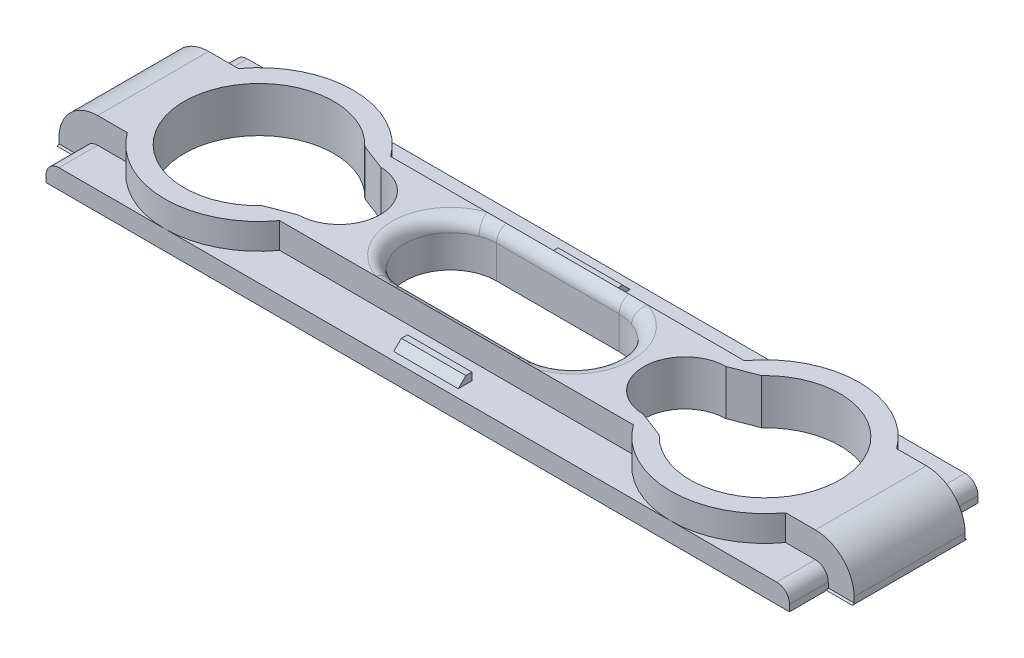
from build123d import *

# Parameters (mm, degrees)
SKETCH_2_W          = 61.6
SKETCH_2_H          = 54.8
EXTRUDE_1_DEPTH     = 1.5
SKETCH_2_4_R        = 1.849118688
EXTRUDE_3_DEPTH     = 3.3
SKETCH_6_W          = 14.6
SKETCH_6_H          = 54.8
EXTRUDE_4_DEPTH     = 3.5
EXTRUDE_START       = -3.5
SKETCH_9_W          = 14.6
SKETCH_9_H          = 54.8
EXTRUDE_6_DEPTH     = 3.5
SKETCH_10_W         = 61.6
SKETCH_10_H         = 14.6
EXTRUDE_7_DEPTH     = 3.5
SKETCH_11_W         = 61.6
SKETCH_11_H         = 14.6
EXTRUDE_8_DEPTH     = 3.5
FILLET_1_R          = 3
CUT_EXTRUDE_1_DEPTH = 3
CUT_EXTRUDE_2_DEPTH = 3
EXTRUDE_9_DEPTH     = 2
EXTRUDE_10_DEPTH    = 2
EXTRUDE_11_DEPTH    = 2
EXTRUDE_12_DEPTH    = 2
EXTRUDE_13_DEPTH    = 2.5
EXTRUDE_14_DEPTH    = 2.5
SKETCH_28_W         = 1.75
SKETCH_28_H         = 12
SKETCH_28_W_2       = 3
SKETCH_28_H_2       = 2.5
EXTRUDE_15_DEPTH    = 3.8
SKETCH_29_W         = 3
SKETCH_29_H         = 3.2
EXTRUDE_16_DEPTH    = 1
CUT_EXTRUDE_4_DEPTH = 1.5
CUT_EXTRUDE_5_DEPTH = 0.2
FILLET_2_R          = 2
FILLET_3_R          = 1.2
FILLET_4_R          = 1
CUT_EXTRUDE_START   = -19.4
SKETCH_32_W         = 75.859078002
SKETCH_32_H         = 54.519170687
CUT_EXTRUDE_6_DEPTH = 19.4


with BuildPart() as part:
    # ｽｹｯﾁ2 → ﾎﾞｽ - 押し出し1 (new body)
    with BuildSketch(Plane.XY):
        with Locations((27, 20)):
            Rectangle(SKETCH_2_W, SKETCH_2_H)
        with BuildLine():
            Line((17.396467493, 32.098090349), (17.396467493, 34.884847493))
            ThreePointArc((17.396467493, 34.884847493), (27, 44.48838), (36.603532507, 34.884847493))
            Line((36.603532507, 34.884847493), (36.603532507, 32.098090349))
            ThreePointArc((36.603532507, 32.098090349), (27, 22.494557841), (17.396467493, 32.098090349))
        make_face(mode=Mode.SUBTRACT)
        with BuildLine():
            Line((17.396467493, 7.901909651), (17.396467493, 5.115152507))
            ThreePointArc((17.396467493, 5.115152507), (27, -4.48838), (36.603532507, 5.115152507))
            Line((36.603532507, 5.115152507), (36.603532507, 7.901909651))
            ThreePointArc((36.603532507, 7.901909651), (27, 17.505442159), (17.396467493, 7.901909651))
        make_face(mode=Mode.SUBTRACT)
        with BuildLine():
            Line((46.11976018, 13.198097812), (44.853626262, 13.198097812))
            ThreePointArc((44.853626262, 13.198097812), (38.051724073, 20), (44.853626262, 26.801902188))
            Line((44.853626262, 26.801902188), (46.11976018, 26.801902188))
            ThreePointArc((46.11976018, 26.801902188), (52.921662369, 20), (46.11976018, 13.198097812))
        make_face(mode=Mode.SUBTRACT)
        with BuildLine():
            Line((7.88023982, 13.198097812), (9.146373738, 13.198097812))
            ThreePointArc((9.146373738, 13.198097812), (15.948275927, 20), (9.146373738, 26.801902188))
            Line((9.146373738, 26.801902188), (7.88023982, 26.801902188))
            ThreePointArc((7.88023982, 26.801902188), (1.078337631, 20), (7.88023982, 13.198097812))
        make_face(mode=Mode.SUBTRACT)
    extrude(amount=EXTRUDE_1_DEPTH)

    # ｽｹｯﾁ2<4> → ﾎﾞｽ - 押し出し3 (add)
    with BuildSketch(Plane.XY):
        with Locations((2, 38)):
            Circle(SKETCH_2_4_R)
        with Locations((2, 2)):
            Circle(SKETCH_2_4_R)
        with Locations((52, 2)):
            Circle(SKETCH_2_4_R)
        with Locations((52, 38)):
            Circle(SKETCH_2_4_R)
    extrude(amount=EXTRUDE_3_DEPTH)

    # ｽｹｯﾁ6 → ﾎﾞｽ - 押し出し4 (add)
    with BuildSketch(Plane.ZY.offset(3.8)):
        with Locations((-5.8, 20)):
            Rectangle(SKETCH_6_W, SKETCH_6_H)
        with BuildLine():
            Line((-3.521492008, 23.1), (-3.521492008, 16.9))
            ThreePointArc((-3.521492008, 16.9), (-5.8, 14.621492008), (-8.078507992, 16.9))
            Line((-8.078507992, 16.9), (-8.078507992, 23.1))
            ThreePointArc((-8.078507992, 23.1), (-5.8, 25.378507992), (-3.521492008, 23.1))
        make_face(mode=Mode.SUBTRACT)
        with BuildLine():
            Line((-9.770178394, 33.871799021), (-8.999779069, 31.862398009))
            ThreePointArc((-8.999779069, 31.862398009), (-5.8, 28.7), (-2.600220931, 31.862398009))
            Line((-2.600220931, 31.862398009), (-1.829821606, 33.871799021))
            ThreePointArc((-1.829821606, 33.871799021), (-5.8, 43.9), (-9.770178394, 33.871799021))
        make_face(mode=Mode.SUBTRACT)
        with BuildLine():
            Line((-2.600220931, 8.137601991), (-1.829821606, 6.128200979))
            ThreePointArc((-1.829821606, 6.128200979), (-5.8, -3.9), (-9.770178394, 6.128200979))
            Line((-9.770178394, 6.128200979), (-8.999779069, 8.137601991))
            ThreePointArc((-8.999779069, 8.137601991), (-5.8, 11.3), (-2.600220931, 8.137601991))
        make_face(mode=Mode.SUBTRACT)
    extrude(amount=-EXTRUDE_4_DEPTH)

    # ｽｹｯﾁ9 → ﾎﾞｽ - 押し出し6 (add)
    with BuildSketch(Plane(origin=(57.8, 0, 0), x_dir=(0, 0, -1), z_dir=(1, 0, 0)).offset(EXTRUDE_START)):
        with Locations((5.8, 20)):
            Rectangle(SKETCH_9_W, SKETCH_9_H)
        with BuildLine():
            Line((8.999779069, 31.862398009), (9.770178394, 33.871799021))
            ThreePointArc((9.770178394, 33.871799021), (5.8, 43.9), (1.829821606, 33.871799021))
            Line((1.829821606, 33.871799021), (2.600220931, 31.862398009))
            ThreePointArc((2.600220931, 31.862398009), (5.8, 28.7), (8.999779069, 31.862398009))
        make_face(mode=Mode.SUBTRACT)
        with BuildLine():
            Line((2.600220931, 8.137601991), (1.829821606, 6.128200979))
            ThreePointArc((1.829821606, 6.128200979), (5.8, -3.9), (9.770178394, 6.128200979))
            Line((9.770178394, 6.128200979), (8.999779069, 8.137601991))
            ThreePointArc((8.999779069, 8.137601991), (5.8, 11.3), (2.600220931, 8.137601991))
        make_face(mode=Mode.SUBTRACT)
        with BuildLine():
            Line((3.521492008, 23.1), (3.521492008, 16.9))
            ThreePointArc((3.521492008, 16.9), (5.8, 14.621492008), (8.078507992, 16.9))
            Line((8.078507992, 16.9), (8.078507992, 23.1))
            ThreePointArc((8.078507992, 23.1), (5.8, 25.378507992), (3.521492008, 23.1))
        make_face(mode=Mode.SUBTRACT)
    extrude(amount=EXTRUDE_6_DEPTH)

    # ｽｹｯﾁ10 → ﾎﾞｽ - 押し出し7 (add)
    with BuildSketch(Plane.XZ.offset(7.4)):
        with Locations((27, -5.8)):
            Rectangle(SKETCH_10_W, SKETCH_10_H)
        with BuildLine():
            Line((22.25, -2.25), (31.75, -2.25))
            ThreePointArc((31.75, -2.25), (35.3, -5.8), (31.75, -9.35))
            Line((31.75, -9.35), (22.25, -9.35))
            ThreePointArc((22.25, -9.35), (18.7, -5.8), (22.25, -2.25))
        make_face(mode=Mode.SUBTRACT)
        with BuildLine():
            Line((11.628200979, -9.770178394), (13.637601991, -8.999779069))
            ThreePointArc((13.637601991, -8.999779069), (16.8, -5.8), (13.637601991, -2.600220931))
            Line((13.637601991, -2.600220931), (11.628200979, -1.829821606))
            ThreePointArc((11.628200979, -1.829821606), (1.6, -5.8), (11.628200979, -9.770178394))
        make_face(mode=Mode.SUBTRACT)
        with BuildLine():
            Line((40.362398009, -2.600220931), (42.371799021, -1.829821606))
            ThreePointArc((42.371799021, -1.829821606), (52.4, -5.8), (42.371799021, -9.770178394))
            Line((42.371799021, -9.770178394), (40.362398009, -8.999779069))
            ThreePointArc((40.362398009, -8.999779069), (37.2, -5.8), (40.362398009, -2.600220931))
        make_face(mode=Mode.SUBTRACT)
    extrude(amount=-EXTRUDE_7_DEPTH)

    # ｽｹｯﾁ11 → ﾎﾞｽ - 押し出し8 (add)
    with BuildSketch(Plane(origin=(0, 47.4, 0), x_dir=(1, 0, 0), z_dir=(0, 1, 0))):
        with Locations((27, 5.8)):
            Rectangle(SKETCH_11_W, SKETCH_11_H)
        with BuildLine():
            Line((40.362398009, 2.600220931), (42.371799021, 1.829821606))
            ThreePointArc((42.371799021, 1.829821606), (52.4, 5.8), (42.371799021, 9.770178394))
            Line((42.371799021, 9.770178394), (40.362398009, 8.999779069))
            ThreePointArc((40.362398009, 8.999779069), (37.2, 5.8), (40.362398009, 2.600220931))
        make_face(mode=Mode.SUBTRACT)
        with BuildLine():
            Line((13.637601991, 8.999779069), (11.628200979, 9.770178394))
            ThreePointArc((11.628200979, 9.770178394), (1.6, 5.8), (11.628200979, 1.829821606))
            Line((11.628200979, 1.829821606), (13.637601991, 2.600220931))
            ThreePointArc((13.637601991, 2.600220931), (16.8, 5.8), (13.637601991, 8.999779069))
        make_face(mode=Mode.SUBTRACT)
        with BuildLine():
            Line((22.25, 2.25), (31.75, 2.25))
            ThreePointArc((31.75, 2.25), (35.3, 5.8), (31.75, 9.35))
            Line((31.75, 9.35), (22.25, 9.35))
            ThreePointArc((22.25, 9.35), (18.7, 5.8), (22.25, 2.25))
        make_face(mode=Mode.SUBTRACT)
    extrude(amount=-EXTRUDE_8_DEPTH)

    # ﾌｨﾚｯﾄ1
    fillet_1_edges = [part.edges().sort_by_distance(p)[0] for p in [
        (57.8, 47.4, -5.8),
        (-3.8, 47.4, -5.8),
        (-3.8, -7.4, -5.8),
        (57.8, -7.4, -5.8),
    ]]
    fillet(fillet_1_edges, radius=FILLET_1_R)

    # ｽｹｯﾁ12 → ｶｯﾄ - 押し出し1 (cut)
    with BuildSketch(Plane(origin=(0, 0, -13.1), x_dir=(-1, 0, 0), z_dir=(0, 0, -1))):
        with BuildLine():
            Line((-54.8, -7.4), (0.8, -7.4))
            ThreePointArc((0.8, -7.4), (2.921320344, -6.521320344), (3.8, -4.4))
            Line((3.8, -4.4), (3.8, 44.4))
            ThreePointArc((3.8, 44.4), (2.921320344, 46.521320344), (0.8, 47.4))
            Line((0.8, 47.4), (-54.8, 47.4))
            ThreePointArc((-54.8, 47.4), (-56.921320344, 46.521320344), (-57.8, 44.4))
            Line((-57.8, 44.4), (-57.8, -4.4))
            ThreePointArc((-57.8, -4.4), (-56.921320344, -6.521320344), (-54.8, -7.4))
        make_face()
        with BuildLine():
            Line((-55.8, 44.4), (-55.8, -4.4))
            ThreePointArc((-55.8, -4.4), (-55.507106781, -5.107106781), (-54.8, -5.4))
            Line((-54.8, -5.4), (0.8, -5.4))
            ThreePointArc((0.8, -5.4), (1.507106781, -5.107106781), (1.8, -4.4))
            Line((1.8, -4.4), (1.8, 44.4))
            ThreePointArc((1.8, 44.4), (1.507106781, 45.107106781), (0.8, 45.4))
            Line((0.8, 45.4), (-54.8, 45.4))
            ThreePointArc((-54.8, 45.4), (-55.507106781, 45.107106781), (-55.8, 44.4))
        make_face(mode=Mode.SUBTRACT)
    extrude(amount=-CUT_EXTRUDE_1_DEPTH, mode=Mode.SUBTRACT)

    # ｽｹｯﾁ22 → ｶｯﾄ - 押し出し2 (cut)
    with BuildSketch(Plane.XY.offset(1.5)):
        with BuildLine():
            Line((-3.8, 44.4), (-3.8, -4.4))
            ThreePointArc((-3.8, -4.4), (-2.921320344, -6.521320344), (-0.8, -7.4))
            Line((-0.8, -7.4), (54.8, -7.4))
            ThreePointArc((54.8, -7.4), (56.921320344, -6.521320344), (57.8, -4.4))
            Line((57.8, -4.4), (57.8, 44.4))
            ThreePointArc((57.8, 44.4), (56.921320344, 46.521320344), (54.8, 47.4))
            Line((54.8, 47.4), (-0.8, 47.4))
            ThreePointArc((-0.8, 47.4), (-2.921320344, 46.521320344), (-3.8, 44.4))
        make_face()
        with BuildLine():
            Line((-1.8, 44.4), (-1.8, -4.4))
            ThreePointArc((-1.8, -4.4), (-1.507106781, -5.107106781), (-0.8, -5.4))
            Line((-0.8, -5.4), (54.8, -5.4))
            ThreePointArc((54.8, -5.4), (55.507106781, -5.107106781), (55.8, -4.4))
            Line((55.8, -4.4), (55.8, 44.4))
            ThreePointArc((55.8, 44.4), (55.507106781, 45.107106781), (54.8, 45.4))
            Line((54.8, 45.4), (-0.8, 45.4))
            ThreePointArc((-0.8, 45.4), (-1.507106781, 45.107106781), (-1.8, 44.4))
        make_face(mode=Mode.SUBTRACT)
    extrude(amount=-CUT_EXTRUDE_2_DEPTH, mode=Mode.SUBTRACT)

    # ｽｹｯﾁ21 → ﾎﾞｽ - 押し出し9 (add)
    with BuildSketch(Plane.XZ.offset(7.4)):
        with BuildLine():
            Line((1.500847518, -10.1), (3.507699909, -10.1))
            ThreePointArc((3.507699909, -10.1), (7.4, -11.6), (11.292300091, -10.1))
            Line((11.292300091, -10.1), (13.299152482, -10.1))
            ThreePointArc((13.299152482, -10.1), (7.4, -13.1), (1.500847518, -10.1))
        make_face()
        with BuildLine():
            Line((11.292300091, -1.5), (13.299152482, -1.5))
            ThreePointArc((13.299152482, -1.5), (7.4, 1.5), (1.500847518, -1.5))
            Line((1.500847518, -1.5), (3.507699909, -1.5))
            ThreePointArc((3.507699909, -1.5), (7.4, 0), (11.292300091, -1.5))
        make_face()
        with BuildLine():
            Line((42.707699909, -10.1), (40.700847518, -10.1))
            ThreePointArc((40.700847518, -10.1), (46.6, -13.1), (52.499152482, -10.1))
            Line((52.499152482, -10.1), (50.492300091, -10.1))
            ThreePointArc((50.492300091, -10.1), (46.6, -11.6), (42.707699909, -10.1))
        make_face()
        with BuildLine():
            Line((52.499152482, -1.5), (50.492300091, -1.5))
            ThreePointArc((50.492300091, -1.5), (46.6, 0), (42.707699909, -1.5))
            Line((42.707699909, -1.5), (40.700847518, -1.5))
            ThreePointArc((40.700847518, -1.5), (46.6, 1.5), (52.499152482, -1.5))
        make_face()
    extrude(amount=-EXTRUDE_9_DEPTH)

    # ｽｹｯﾁ23 → ﾎﾞｽ - 押し出し10 (add)
    with BuildSketch(Plane(origin=(0, 47.4, 0), x_dir=(1, 0, 0), z_dir=(0, 1, 0))):
        with BuildLine():
            Line((1.500847518, 10.1), (3.507699909, 10.1))
            ThreePointArc((3.507699909, 10.1), (7.4, 11.6), (11.292300091, 10.1))
            Line((11.292300091, 10.1), (13.299152482, 10.1))
            ThreePointArc((13.299152482, 10.1), (7.4, 13.1), (1.500847518, 10.1))
        make_face()
        with BuildLine():
            Line((52.499152482, 1.5), (50.492300091, 1.5))
            ThreePointArc((50.492300091, 1.5), (46.6, 0), (42.707699909, 1.5))
            Line((42.707699909, 1.5), (40.700847518, 1.5))
            ThreePointArc((40.700847518, 1.5), (46.6, -1.5), (52.499152482, 1.5))
        make_face()
        with BuildLine():
            Line((40.700847518, 10.1), (42.707699909, 10.1))
            ThreePointArc((42.707699909, 10.1), (46.6, 11.6), (50.492300091, 10.1))
            Line((50.492300091, 10.1), (52.499152482, 10.1))
            ThreePointArc((52.499152482, 10.1), (46.6, 13.1), (40.700847518, 10.1))
        make_face()
        with BuildLine():
            Line((13.299152482, 1.5), (11.292300091, 1.5))
            ThreePointArc((11.292300091, 1.5), (7.4, 0), (3.507699909, 1.5))
            Line((3.507699909, 1.5), (1.500847518, 1.5))
            ThreePointArc((1.500847518, 1.5), (7.4, -1.5), (13.299152482, 1.5))
        make_face()
    extrude(amount=-EXTRUDE_10_DEPTH)

    # ｽｹｯﾁ24 → ﾎﾞｽ - 押し出し11 (add)
    with BuildSketch(Plane(origin=(57.8, 0, 0), x_dir=(0, 0, -1), z_dir=(1, 0, 0))):
        with BuildLine():
            Line((1.5, 41.992300091), (1.5, 43.999152482))
            ThreePointArc((1.5, 43.999152482), (-1.5, 38.1), (1.5, 32.200847518))
            Line((1.5, 32.200847518), (1.5, 34.207699909))
            ThreePointArc((1.5, 34.207699909), (0, 38.1), (1.5, 41.992300091))
        make_face()
        with BuildLine():
            Line((10.1, 32.200847518), (10.1, 34.207699909))
            ThreePointArc((10.1, 34.207699909), (11.6, 38.1), (10.1, 41.992300091))
            Line((10.1, 41.992300091), (10.1, 43.999152482))
            ThreePointArc((10.1, 43.999152482), (13.1, 38.1), (10.1, 32.200847518))
        make_face()
        with BuildLine():
            Line((10.1, -1.992300091), (10.1, -3.999152482))
            ThreePointArc((10.1, -3.999152482), (13.1, 1.9), (10.1, 7.799152482))
            Line((10.1, 7.799152482), (10.1, 5.792300091))
            ThreePointArc((10.1, 5.792300091), (11.6, 1.9), (10.1, -1.992300091))
        make_face()
        with BuildLine():
            Line((1.5, 7.799152482), (1.5, 5.792300091))
            ThreePointArc((1.5, 5.792300091), (0, 1.9), (1.5, -1.992300091))
            Line((1.5, -1.992300091), (1.5, -3.999152482))
            ThreePointArc((1.5, -3.999152482), (-1.5, 1.9), (1.5, 7.799152482))
        make_face()
    extrude(amount=-EXTRUDE_11_DEPTH)

    # ｽｹｯﾁ25 → ﾎﾞｽ - 押し出し12 (add)
    with BuildSketch(Plane.ZY.offset(3.8)):
        with BuildLine():
            Line((-1.5, 43.999152482), (-1.5, 41.992300091))
            ThreePointArc((-1.5, 41.992300091), (0, 38.1), (-1.5, 34.207699909))
            Line((-1.5, 34.207699909), (-1.5, 32.200847518))
            ThreePointArc((-1.5, 32.200847518), (1.5, 38.1), (-1.5, 43.999152482))
        make_face()
        with BuildLine():
            Line((-1.5, 7.799152482), (-1.5, 5.792300091))
            ThreePointArc((-1.5, 5.792300091), (0, 1.9), (-1.5, -1.992300091))
            Line((-1.5, -1.992300091), (-1.5, -3.999152482))
            ThreePointArc((-1.5, -3.999152482), (1.5, 1.9), (-1.5, 7.799152482))
        make_face()
        with BuildLine():
            Line((-10.1, -3.999152482), (-10.1, -1.992300091))
            ThreePointArc((-10.1, -1.992300091), (-11.6, 1.9), (-10.1, 5.792300091))
            Line((-10.1, 5.792300091), (-10.1, 7.799152482))
            ThreePointArc((-10.1, 7.799152482), (-13.1, 1.9), (-10.1, -3.999152482))
        make_face()
        with BuildLine():
            Line((-10.1, 32.200847518), (-10.1, 34.207699909))
            ThreePointArc((-10.1, 34.207699909), (-11.6, 38.1), (-10.1, 41.992300091))
            Line((-10.1, 41.992300091), (-10.1, 43.999152482))
            ThreePointArc((-10.1, 43.999152482), (-13.1, 38.1), (-10.1, 32.200847518))
        make_face()
    extrude(amount=-EXTRUDE_12_DEPTH)

    # ｽｹｯﾁ26 → ﾎﾞｽ - 押し出し13 (add, symmetric)
    with BuildSketch(Plane(origin=(0, 20, 0), x_dir=(1, 0, 0), z_dir=(0, 1, 0))):
        Polygon((56.388664164, -0.246601917), (56.388664164, 0.223398083), (55.8, 0.223398083), (55.8, -0.835266081), align=None)
        Polygon((55.8, 11.376601917), (56.388664164, 11.376601917), (56.388664164, 11.846601917), (55.8, 12.435266081), align=None)
        Polygon((-2.388664164, 11.846601917), (-2.388664164, 11.376601917), (-1.8, 11.376601917), (-1.8, 12.435266081), align=None)
        Polygon((-1.8, 0.223398083), (-2.388664164, 0.223398083), (-2.388664164, -0.246601917), (-1.8, -0.835266081), align=None)
    extrude(amount=EXTRUDE_13_DEPTH, both=True)

    # ｽｹｯﾁ27 → ﾎﾞｽ - 押し出し14 (add, symmetric)
    with BuildSketch(Plane.ZY.offset(-27)):
        Polygon((0.271335836, 45.988664164), (-0.198664164, 45.988664164), (-0.198664164, 45.4), (0.86, 45.4), align=None)
        Polygon((-11.401335836, 45.4), (-12.46, 45.4), (-11.871335836, 45.988664164), (-11.401335836, 45.988664164), align=None)
        Polygon((-11.401335836, -5.4), (-11.401335836, -5.988664164), (-11.871335836, -5.988664164), (-12.46, -5.4), align=None)
        Polygon((-0.198664164, -5.988664164), (-0.198664164, -5.4), (0.86, -5.4), (0.271335836, -5.988664164), align=None)
    extrude(amount=EXTRUDE_14_DEPTH, both=True)

    # ｽｹｯﾁ28 → ﾎﾞｽ - 押し出し15 (add)
    with BuildSketch(Plane.XY.offset(1.5)):
        with Locations((-0.925, 20)):
            Rectangle(SKETCH_28_W, SKETCH_28_H)
        with Locations((54.925, 20)):
            Rectangle(SKETCH_28_W, SKETCH_28_H)
        with Locations((5.85, 41.25)):
            Rectangle(SKETCH_28_W_2, SKETCH_28_H_2)
        with Locations((5.85, -1.25)):
            Rectangle(SKETCH_28_W_2, SKETCH_28_H_2)
        with Locations((48.15, -1.25)):
            Rectangle(SKETCH_28_W_2, SKETCH_28_H_2)
        with Locations((48.15, 41.25)):
            Rectangle(SKETCH_28_W_2, SKETCH_28_H_2)
    extrude(amount=EXTRUDE_15_DEPTH)

    # ｽｹｯﾁ29 → ﾎﾞｽ - 押し出し16 (add)
    with BuildSketch(Plane.XY.offset(5.3)):
        with Locations((5.85, 40.9)):
            Rectangle(SKETCH_29_W, SKETCH_29_H)
        with Locations((5.85, -0.9)):
            Rectangle(SKETCH_29_W, SKETCH_29_H)
        with Locations((48.15, -0.9)):
            Rectangle(SKETCH_29_W, SKETCH_29_H)
        with Locations((48.15, 40.9)):
            Rectangle(SKETCH_29_W, SKETCH_29_H)
    extrude(amount=EXTRUDE_16_DEPTH)

    # ｽｹｯﾁ30 → ｶｯﾄ - 押し出し4 (cut)
    with BuildSketch(Plane.XY.offset(1.5)):
        Polygon((4.35, 42.5), (4.35, 34.5), (3.85, 34.5), (3.85, 43), (7.85, 43), (7.85, 34.5), (7.35, 34.5), (7.35, 42.5), align=None)
        Polygon((7.35, 5.5), (7.85, 5.5), (7.85, -3), (3.85, -3), (3.85, 5.5), (4.35, 5.5), (4.35, -2.5), (7.35, -2.5), align=None)
        Polygon((49.65, -2.5), (49.65, 5.5), (50.15, 5.5), (50.15, -3), (46.15, -3), (46.15, 5.5), (46.65, 5.5), (46.65, -2.5), align=None)
        Polygon((46.65, 34.5), (46.15, 34.5), (46.15, 43), (50.15, 43), (50.15, 34.5), (49.65, 34.5), (49.65, 42.5), (46.65, 42.5), align=None)
    extrude(amount=-CUT_EXTRUDE_4_DEPTH, mode=Mode.SUBTRACT)

    # ｽｹｯﾁ31 → ｶｯﾄ - 押し出し5 (cut)
    with BuildSketch(Plane(origin=(0, 0, 0), x_dir=(-1, 0, 0), z_dir=(0, 0, -1))):
        with BuildLine():
            Line((0.3, -3.9), (0.3, 1.9))
            Line((0.3, 1.9), (0.3, 38.1))
            Line((0.3, 38.1), (0.3, 43.9))
            Line((0.3, 43.9), (-7.4, 43.9))
            Line((-7.4, 43.9), (-23.690187032, 43.9))
            ThreePointArc((-23.690187032, 43.9), (-19.125556114, 40.382207777), (-17.396467493, 34.884847493))
            Line((-17.396467493, 34.884847493), (-17.396467493, 32.098090349))
            ThreePointArc((-17.396467493, 32.098090349), (-27, 22.494557841), (-36.603532507, 32.098090349))
            Line((-36.603532507, 32.098090349), (-36.603532507, 34.884847493))
            ThreePointArc((-36.603532507, 34.884847493), (-34.874443886, 40.382207777), (-30.309812968, 43.9))
            Line((-30.309812968, 43.9), (-46.6, 43.9))
            Line((-46.6, 43.9), (-54.3, 43.9))
            Line((-54.3, 43.9), (-54.3, 38.1))
            Line((-54.3, 38.1), (-54.3, 1.9))
            Line((-54.3, 1.9), (-54.3, -3.9))
            Line((-54.3, -3.9), (-46.6, -3.9))
            Line((-46.6, -3.9), (-30.309812968, -3.9))
            ThreePointArc((-30.309812968, -3.9), (-34.874443886, -0.382207777), (-36.603532507, 5.115152507))
            Line((-36.603532507, 5.115152507), (-36.603532507, 7.901909651))
            ThreePointArc((-36.603532507, 7.901909651), (-27, 17.505442159), (-17.396467493, 7.901909651))
            Line((-17.396467493, 7.901909651), (-17.396467493, 5.115152507))
            ThreePointArc((-17.396467493, 5.115152507), (-19.125556114, -0.382207777), (-23.690187032, -3.9))
            Line((-23.690187032, -3.9), (-7.4, -3.9))
            Line((-7.4, -3.9), (0.3, -3.9))
        make_face()
    extrude(amount=-CUT_EXTRUDE_5_DEPTH, mode=Mode.SUBTRACT)

    # ﾌｨﾚｯﾄ2
    fillet_2_edges = [part.edges().sort_by_distance(p)[0] for p in [
        (5.85, 40, 1.5),
        (5.85, 0, 1.5),
        (48.15, 0, 1.5),
        (48.15, 40, 1.5),
    ]]
    fillet(fillet_2_edges, radius=FILLET_2_R)

    # ﾌｨﾚｯﾄ3
    fillet_3_edges = [part.edges().sort_by_distance(p)[0] for p in [
        (54.05, 20, 1.5),
        (-0.05, 20, 1.5),
    ]]
    fillet(fillet_3_edges, radius=FILLET_3_R)

    # ﾌｨﾚｯﾄ4
    fillet_4_edges = [part.edges().sort_by_distance(p)[0] for p in [
        (18.7, 47.4, -5.8),
        (35.3, 47.4, -5.8),
        (18.7, -7.4, -5.8),
        (35.3, -7.4, -5.8),
    ]]
    fillet(fillet_4_edges, radius=FILLET_4_R)

    # ｽｹｯﾁ32 → ｶｯﾄ - 押し出し6 (cut)
    with BuildSketch(Plane(origin=(0, 0, -13.1), x_dir=(-1, 0, 0), z_dir=(0, 0, -1)).offset(CUT_EXTRUDE_START)):
        with Locations((-26.195807366, 16.640414657)):
            Rectangle(SKETCH_32_W, SKETCH_32_H)
    extrude(amount=CUT_EXTRUDE_6_DEPTH, mode=Mode.SUBTRACT)


solid = part.part
